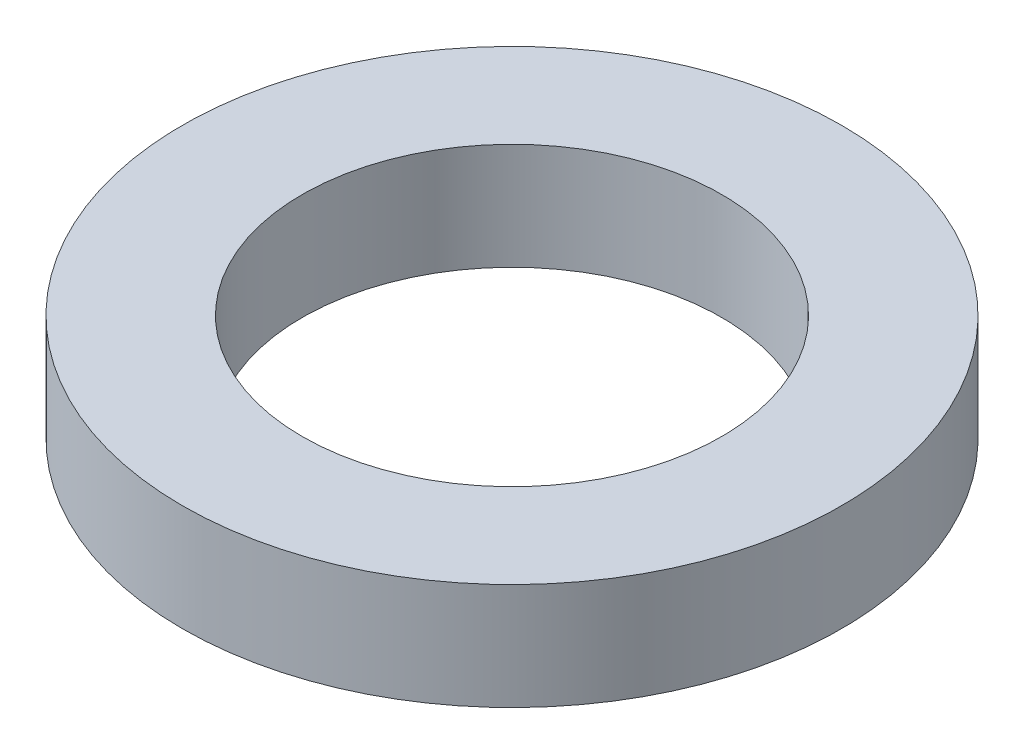
from build123d import *

# Parameters (mm, degrees)
SKETCH1_R           = 12.573
SKETCH1_R_2         = 8.001
BOSS_EXTRUDE1_DEPTH = 4.064


with BuildPart() as part:
    # Sketch1 → Boss-Extrude1 (new body)
    with BuildSketch(Plane(origin=(0, 0, 0), x_dir=(1, 0, 0), z_dir=(0, 1, 0))):
        with Locations(Location((0, 0, 0), (0, 0, 270))):  # turned: the seam where the file's is
            Circle(SKETCH1_R)
        with Locations(Location((0, 0, 0), (0, 0, 270))):  # turned: the seam where the file's is
            Circle(SKETCH1_R_2, mode=Mode.SUBTRACT)
    extrude(amount=BOSS_EXTRUDE1_DEPTH)


solid = part.part
